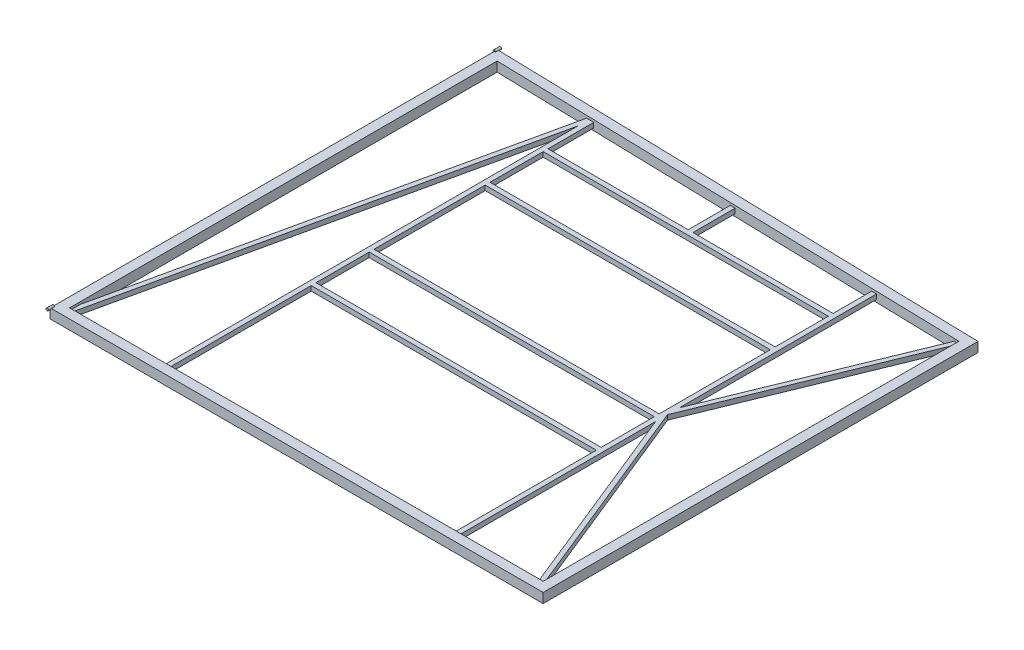
from build123d import *

# Parameters (mm, degrees)
SKETCH2_W           = 50.8
SKETCH2_H           = 50.8
SKETCH2_W_2         = 44.45
SKETCH2_H_2         = 44.45
BOSS_EXTRUDE1_REACH = 2301.343
SKETCH3_W           = 25.4
SKETCH3_H           = 25.4
SKETCH3_W_2         = 19.05
SKETCH3_H_2         = 19.05
SKETCH4_W           = 25.4
SKETCH4_H           = 25.4
SKETCH4_W_2         = 19.05
SKETCH4_H_2         = 19.05
BOSS_EXTRUDE2_DEPTH = 1498.6
SKETCH5_W           = 25.4
SKETCH5_H           = 25.4
SKETCH5_W_2         = 19.05
SKETCH5_H_2         = 19.05
BOSS_EXTRUDE3_REACH = 307.443
SKETCH11_W          = 25.4
SKETCH11_H          = 25.4
SKETCH11_W_2        = 19.05
SKETCH11_H_2        = 19.05
SKETCH13_W          = 25.4
SKETCH13_H          = 25.4
SKETCH13_W_2        = 19.05
SKETCH13_H_2        = 19.05
SKETCH15_R          = 6.35
BOSS_EXTRUDE4_DEPTH = 15.875
SKETCH16_R          = 6.35
BOSS_EXTRUDE5_DEPTH = 15.875


with BuildPart() as part:
    # Sweep1: sweep along a path in Sketch1
    with BuildLine(Plane(origin=(0, 0, 0), x_dir=(1, 0, 0), z_dir=(0, 1, 0))) as sweep1_path:
        Line((0, 2298.7), (0, 0))
        Line((0, 0), (2540, 0))
        Line((2540, 0), (2540, 2235.2))
        Line((2540, 2235.2), (0, 2298.7))
    # Sketch2 → Sweep1 (sweep)
    with BuildSketch(Plane.XY.offset(-1016)):
        Rectangle(SKETCH2_W, SKETCH2_H)
        Rectangle(SKETCH2_W_2, SKETCH2_H_2, mode=Mode.SUBTRACT)
    sweep(path=sweep1_path.line, transition=Transition.RIGHT)

    # Boss-Extrude1: up to this face of the body (flat: up to its plane)
    boss_extrude1_end = Plane(part.part.faces().sort_by_distance((1270, 0, -2241.54206374))[0])
    # Sketch3 → Boss-Extrude1 (add, up to the picked face)
    with BuildSketch(Plane(origin=(0, 0, -25.4), x_dir=(-1, 0, 0), z_dir=(0, 0, -1)), mode=Mode.PRIVATE) as boss_extrude1_sk1:
        with Locations((-533.4, 0)):
            Rectangle(SKETCH3_W, SKETCH3_H)
        with Locations((-533.4, 0)):
            Rectangle(SKETCH3_W_2, SKETCH3_H_2, mode=Mode.SUBTRACT)
    boss_extrude1_tool1 = split(extrude(boss_extrude1_sk1.sketch, amount=BOSS_EXTRUDE1_REACH, mode=Mode.PRIVATE), bisect_by=boss_extrude1_end, keep=Keep.BOTH, mode=Mode.PRIVATE)
    add(boss_extrude1_tool1.solids().sort_by_distance((521.05921, 0, -25.4))[0])
    # Sketch3 → Boss-Extrude1 (add, up to the picked face)
    with BuildSketch(Plane(origin=(0, 0, -25.4), x_dir=(-1, 0, 0), z_dir=(0, 0, -1)), mode=Mode.PRIVATE) as boss_extrude1_sk2:
        with Locations((-2057.4, 0)):
            Rectangle(SKETCH3_W, SKETCH3_H)
        with Locations((-2057.4, 0)):
            Rectangle(SKETCH3_W_2, SKETCH3_H_2, mode=Mode.SUBTRACT)
    boss_extrude1_tool2 = split(extrude(boss_extrude1_sk2.sketch, amount=BOSS_EXTRUDE1_REACH, mode=Mode.PRIVATE), bisect_by=boss_extrude1_end, keep=Keep.BOTH, mode=Mode.PRIVATE)
    add(boss_extrude1_tool2.solids().sort_by_distance((2057.4, -12.34079, -25.4))[0])

    # Sketch4 → Boss-Extrude2 (add)
    with BuildSketch(Plane(origin=(546.1, 0, 0), x_dir=(0, 0, -1), z_dir=(1, 0, 0))):
        with Locations((787.4, 0)):
            Rectangle(SKETCH4_W, SKETCH4_H)
        with Locations((787.4, 0)):
            Rectangle(SKETCH4_W_2, SKETCH4_H_2, mode=Mode.SUBTRACT)
        with Locations((1092.2, 0)):
            Rectangle(SKETCH4_W, SKETCH4_H)
        with Locations((1092.2, 0)):
            Rectangle(SKETCH4_W_2, SKETCH4_H_2, mode=Mode.SUBTRACT)
        with Locations((1701.8, 0)):
            Rectangle(SKETCH4_W, SKETCH4_H)
        with Locations((1701.8, 0)):
            Rectangle(SKETCH4_W_2, SKETCH4_H_2, mode=Mode.SUBTRACT)
        with Locations((2006.6, 0)):
            Rectangle(SKETCH4_W, SKETCH4_H)
        with Locations((2006.6, 0)):
            Rectangle(SKETCH4_W_2, SKETCH4_H_2, mode=Mode.SUBTRACT)
    extrude(amount=BOSS_EXTRUDE2_DEPTH)

    # Sweep2: sweep along a path in Sketch6
    with BuildLine(Plane(origin=(0, 25.4, 0), x_dir=(1, 0, 0), z_dir=(0, 1, 0))) as sweep2_path:
        Line((25.4, 25.4), (520.7, 2260.27456374))
    # Sketch5 → Sweep2 (sweep)
    with BuildSketch(Plane(origin=(0, 0, -25.4), x_dir=(-1, 0, 0), z_dir=(0, 0, -1))):
        with Locations((-25.4, 0)):
            Rectangle(SKETCH5_W, SKETCH5_H)
        with Locations((-25.4, 0)):
            Rectangle(SKETCH5_W_2, SKETCH5_H_2, mode=Mode.SUBTRACT)
    sweep(path=sweep2_path.line)

    # Boss-Extrude3: up to this face of the body (flat: up to its plane)
    boss_extrude3_end = Plane(part.part.faces().sort_by_distance((1269.73814433, 0, -2241.548610131))[0])
    # Sketch11 → Boss-Extrude3 (add, up to the picked face)
    with BuildSketch(Plane(origin=(0, 0, -2019.3), x_dir=(-1, 0, 0), z_dir=(0, 0, -1)), mode=Mode.PRIVATE) as boss_extrude3_sk1:
        with Locations((-1295.4, 0)):
            Rectangle(SKETCH11_W, SKETCH11_H)
        with Locations((-1295.4, 0)):
            Rectangle(SKETCH11_W_2, SKETCH11_H_2, mode=Mode.SUBTRACT)
    boss_extrude3_tool1 = split(extrude(boss_extrude3_sk1.sketch, amount=BOSS_EXTRUDE3_REACH, mode=Mode.PRIVATE), bisect_by=boss_extrude3_end, keep=Keep.BOTH, mode=Mode.PRIVATE)
    add(boss_extrude3_tool1.solids().sort_by_distance((1295.4, -12.34079, -2019.3))[0])

    # Sweep6: sweep along a path in Sketch14
    with BuildLine(Plane(origin=(0, 25.4, 0), x_dir=(1, 0, 0), z_dir=(0, 1, 0))) as sweep6_path:
        Line((2514.6, 25.4), (2070.1, 1123.46978187))
        Line((2070.1, 1123.46978187), (2514.6, 2210.42706374))
    # Sketch13 → Sweep6 (sweep)
    with BuildSketch(Plane(origin=(0, 0, -25.4), x_dir=(-1, 0, 0), z_dir=(0, 0, -1))):
        with Locations((-2501.9, 0)):
            Rectangle(SKETCH13_W, SKETCH13_H)
        with Locations((-2501.9, 0)):
            Rectangle(SKETCH13_W_2, SKETCH13_H_2, mode=Mode.SUBTRACT)
    sweep(path=sweep6_path.line, transition=Transition.RIGHT)

    # Sketch15 → Boss-Extrude4 (add, symmetric)
    with BuildSketch(Plane.XY.offset(-2324.74293626)):
        with Locations((-25.4, 25.4)):
            Circle(SKETCH15_R)
    extrude(amount=BOSS_EXTRUDE4_DEPTH, both=True)

    # Sketch16 → Boss-Extrude5 (add, symmetric)
    with BuildSketch(Plane.XY.offset(25.4)):
        with Locations((-25.4, 25.4)):
            Circle(SKETCH16_R)
    extrude(amount=BOSS_EXTRUDE5_DEPTH, both=True)


solid = part.part
